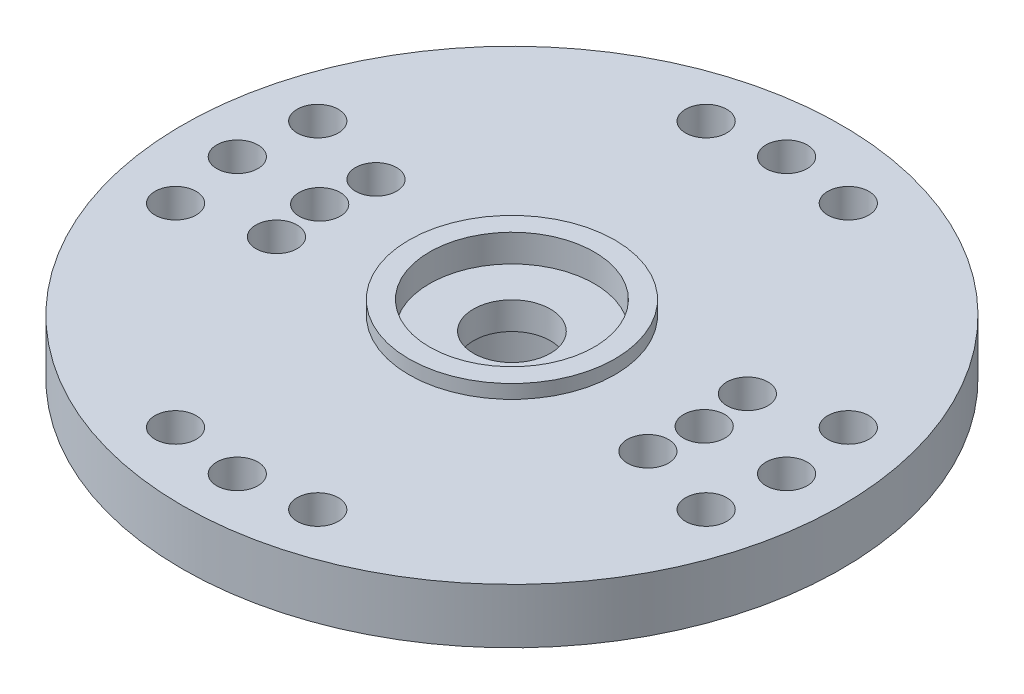
from build123d import *

# Parameters (mm, degrees)
F_1_5_1_5_DIAMETER_HOLE1_D     = 1.5
F_1_5_1_5_DIAMETER_HOLE1_DEPTH = 2
CIRPATTERN1_COUNT              = 4
SKETCH4_R                      = 3
CUT_EXTRUDE1_DEPTH             = 1
SKETCH5_R                      = 3
CUT_EXTRUDE2_DEPTH             = 3
F_1_5_1_5_DIAMETER_HOLE2_D     = 1.5
F_1_5_1_5_DIAMETER_HOLE2_DEPTH = 2
CIRPATTERN2_COUNT              = 2


with BuildPart() as part:
    # Sketch1 → Revolve1 (revolve)
    with BuildSketch(Plane.XY):
        Polygon((-12, 0), (-3.75, 0), (-3.75, 0.5), (-1.4, 0.5), (-1.4, -4.5), (-4.45, -4.5), (-4.45, -2), (-12, -2), align=None)
    revolve(axis=Axis((0, 0, 0), (0, -1, 0)))

    # Ø1.5 (1.5) Diameter Hole1
    with Locations(Plane(origin=(0, 0, 0), x_dir=(-1, 0, 0), z_dir=(0, 1, 0))):
        with Locations((0, -10), (2.588190451, -9.659258263), (-2.588190451, -9.659258263)):
            f_1_5_1_5_diameter_hole1 = Hole(F_1_5_1_5_DIAMETER_HOLE1_D / 2, depth=F_1_5_1_5_DIAMETER_HOLE1_DEPTH)

    # CirPattern1: Ø1.5 (1.5) Diameter Hole1 ×4 about axis
    cirpattern1_axis = Axis((0, 0, 0), (0, 1, 0))
    for i in range(1, CIRPATTERN1_COUNT):
        add(f_1_5_1_5_diameter_hole1.rotate(cirpattern1_axis, i * 360 / CIRPATTERN1_COUNT), mode=Mode.SUBTRACT)

    # Sketch4 → Cut-Extrude1 (cut)
    with BuildSketch(Plane(origin=(0, 0.5, 0), x_dir=(-1, 0, 0), z_dir=(0, 1, 0))):
        Circle(SKETCH4_R)
    extrude(amount=-CUT_EXTRUDE1_DEPTH, mode=Mode.SUBTRACT)

    # Sketch5 → Cut-Extrude2 (cut)
    with BuildSketch(Plane.XZ.offset(4.5)):
        Circle(SKETCH5_R)
    extrude(amount=-CUT_EXTRUDE2_DEPTH, mode=Mode.SUBTRACT)

    # Ø1.5 (1.5) Diameter Hole2
    with Locations(Plane(origin=(0, 0, 0), x_dir=(-1, 0, 0), z_dir=(0, 1, 0))):
        with Locations((6.761480784, -1.811733316), (7, 0), (6.761480784, 1.811733316)):
            f_1_5_1_5_diameter_hole2 = Hole(F_1_5_1_5_DIAMETER_HOLE2_D / 2, depth=F_1_5_1_5_DIAMETER_HOLE2_DEPTH)

    # CirPattern2: Ø1.5 (1.5) Diameter Hole2 ×2 about axis
    cirpattern2_axis = Axis((0, 0, 0), (0, 1, 0))
    for i in range(1, CIRPATTERN2_COUNT):
        add(f_1_5_1_5_diameter_hole2.rotate(cirpattern2_axis, i * 360 / CIRPATTERN2_COUNT), mode=Mode.SUBTRACT)


solid = part.part
